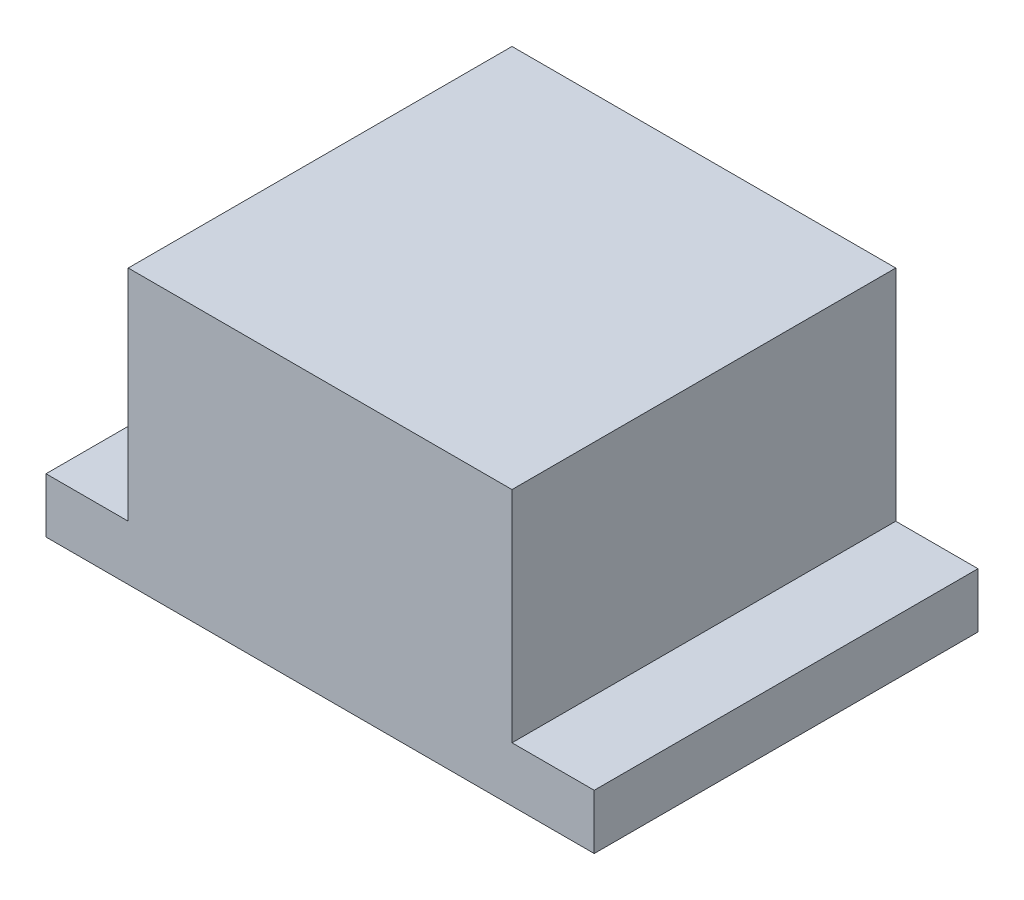
from build123d import *

# Parameters (mm, degrees)
EXTRUDE_1_DEPTH = 3.5


with BuildPart() as part:
    # Эскиз1 → Бобышка-Вытянуть1 (new body)
    with BuildSketch(Plane.XY):
        Polygon((-2.5, 0), (2.5, 0), (2.5, 0.5), (1.75, 0.5), (1.75, 2.5), (-1.75, 2.5), (-1.75, 0.5), (-2.5, 0.5), align=None)
    extrude(amount=EXTRUDE_1_DEPTH)


solid = part.part
